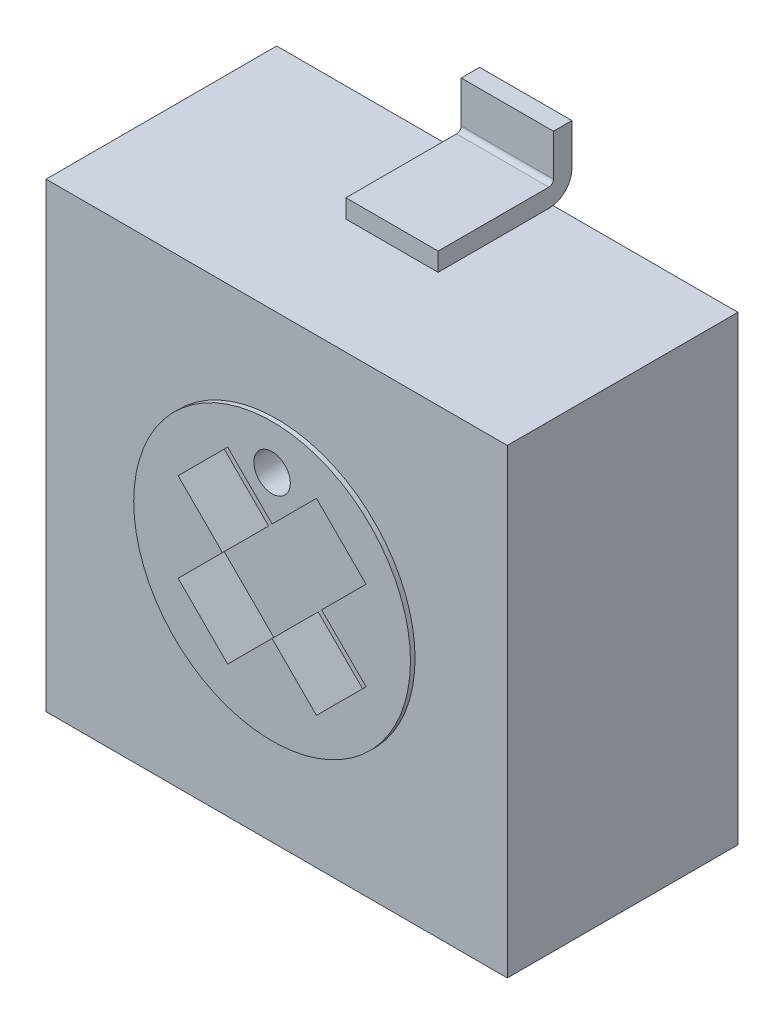
from build123d import *

# Parameters (mm, degrees)
SKETCH1_W           = 5
SKETCH1_H           = 5
BOSS_EXTRUDE1_DEPTH = 2.5
EXTRUDE_THIN1_DEPTH = 0.5
EXTRUDE_THIN2_DEPTH = 0.45
LPATTERN1_COUNT     = 2
LPATTERN1_PITCH     = 2.3
SKETCH4_R           = 1.5
BOSS_EXTRUDE2_DEPTH = 0.05
SKETCH5_R           = 0.197706898
CUT_EXTRUDE2_DEPTH  = 0.5


with BuildPart() as part:
    # Sketch1 → Boss-Extrude1 (new body)
    with BuildSketch(Plane.XY):
        with Locations((2.5, 2.5)):
            Rectangle(SKETCH1_W, SKETCH1_H)
    extrude(amount=BOSS_EXTRUDE1_DEPTH)

    # Sketch2 → Extrude-Thin1 (add, symmetric)
    with BuildSketch(Plane(origin=(2.5, 0, 0), x_dir=(0, 0, -1), z_dir=(1, 0, 0))):
        with BuildLine():
            Line((-1.25, 5), (-0.05, 5))
            ThreePointArc((-0.05, 5), (0.126776695, 5.073223305), (0.2, 5.25))
            Line((0.2, 5.25), (0.2, 5.7))
            Line((0.2, 5.7), (0, 5.7))
            Line((0, 5.7), (0, 5.25))
            ThreePointArc((0, 5.25), (-0.014644661, 5.214644661), (-0.05, 5.2))
            Line((-0.05, 5.2), (-1.25, 5.2))
            Line((-1.25, 5.2), (-1.25, 5))
        make_face()
    extrude(amount=EXTRUDE_THIN1_DEPTH, both=True)

    # Sketch3 → Extrude-Thin2 (add, symmetric)
    with BuildSketch(Plane(origin=(1.35, 0, 0), x_dir=(0, 0, -1), z_dir=(1, 0, 0))):
        with BuildLine():
            Line((-1.25, 0), (-0.05, 0))
            ThreePointArc((-0.05, 0), (0.126776695, -0.073223305), (0.2, -0.25))
            Line((0.2, -0.25), (0.2, -0.7))
            Line((0.2, -0.7), (0, -0.7))
            Line((0, -0.7), (0, -0.25))
            ThreePointArc((0, -0.25), (-0.014644661, -0.214644661), (-0.05, -0.2))
            Line((-0.05, -0.2), (-1.25, -0.2))
            Line((-1.25, -0.2), (-1.25, 0))
        make_face()
    extrude_thin2 = extrude(amount=EXTRUDE_THIN2_DEPTH, both=True)

    # LPattern1: Extrude-Thin2 ×2
    with Locations(*[(i * LPATTERN1_PITCH, 0, 0) for i in range(1, LPATTERN1_COUNT)]):
        add(extrude_thin2)

    # Sketch4 → Boss-Extrude2 (add)
    with BuildSketch(Plane.XY.offset(2.5)):
        with Locations((2.5, 2.5)):
            Circle(SKETCH4_R)
    extrude(amount=BOSS_EXTRUDE2_DEPTH)

    # Sketch5 → Cut-Extrude2 (cut)
    with BuildSketch(Plane.XY.offset(2.55)):
        with Locations((2.5, 3.518700577)):
            Circle(SKETCH5_R)
        Polygon((2.018700577, 3.518700577), (2.5, 3.037401154), (2.981299423, 3.518700577), (3.518700577, 2.981299423), (3.037401154, 2.5), (3.518700577, 2.018700577), (2.981299423, 1.481299423), (2.5, 1.962598846), (2.018700577, 1.481299423), (1.481299423, 2.018700577), (1.962598846, 2.5), (1.481299423, 2.981299423), align=None)
    extrude(amount=-CUT_EXTRUDE2_DEPTH, mode=Mode.SUBTRACT)


solid = part.part
